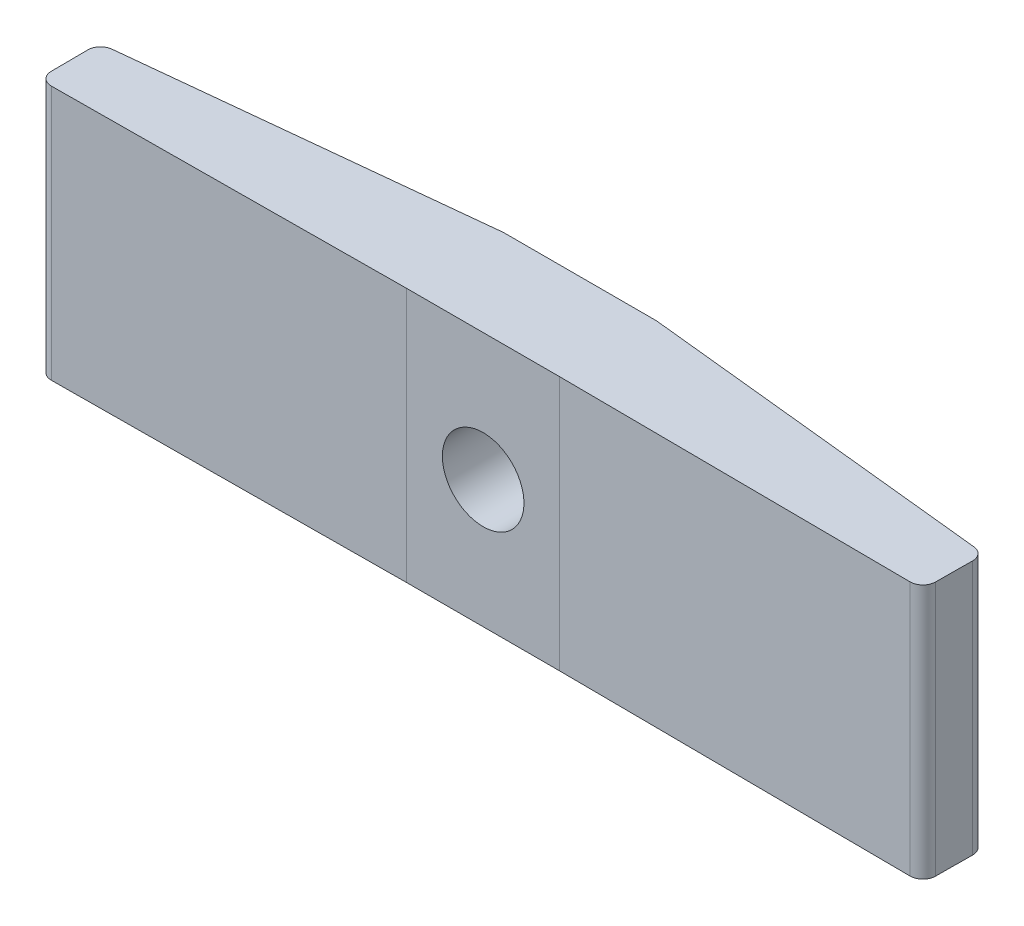
from build123d import *

# Parameters (mm, degrees)
BOSS_EXTRUDE1_DEPTH       = 10
FILLET2_R                 = 0.5
SKETCH2_R                 = 1.6
CUT_EXTRUDE1_DEPTH        = 4.896527904
REVISION_INDICATION_DEPTH = 0.4


with BuildPart() as part:
    # Sketch1 → Boss-Extrude1 (new body)
    with BuildSketch(Plane(origin=(0, 0, 0), x_dir=(1, 0, 0), z_dir=(0, 1, 0))):
        Polygon((20.35, 0.1), (14.35, 0.1), (0, 0), (-0.016724739, 2.4), (14.35, 3.9), (20.35, 3.9), (34.716724739, 2.4), (34.7, 0), align=None)
    extrude(amount=BOSS_EXTRUDE1_DEPTH)

    # Fillet2
    fillet2_edges = [part.edges().sort_by_distance(p)[0] for p in [
        (-0.016724739, 5, -2.4),
        (34.716724739, 5, -2.4),
        (34.7, 5, 0),
        (0, 5, 0),
    ]]
    fillet(fillet2_edges, radius=FILLET2_R)

    # Sketch2 → Cut-Extrude1 (cut, through all)
    with BuildSketch(Plane(origin=(0, 0, -3.9), x_dir=(-1, 0, 0), z_dir=(0, 0, -1))):
        with Locations((-17.35, 5)):
            Circle(SKETCH2_R)
    extrude(amount=-CUT_EXTRUDE1_DEPTH, mode=Mode.SUBTRACT)

    # Sketch5 → revision indication (add)
    with BuildSketch(Plane(origin=(-0.248057274, 0, -2.375847049), x_dir=(-0.994593653, 0, 0.103843465), z_dir=(-0.103843465, 0, -0.994593653))):
        with BuildLine():
            add(Edge.make_bspline(
                [(-1.785308798, 1.976923077), (-1.749947985, 1.974821832), (-1.680627244, 1.970702586), (-1.580407683, 1.942442049), (-1.489703086, 1.892261337), (-1.40890887, 1.825381725), (-1.342312834, 1.744291021), (-1.290343795, 1.654309873), (-1.262329436, 1.553251269), (-1.258240196, 1.483528859), (-1.256142132, 1.44775641)],
                knots=[0, 0, 0, 0, 0.000106068, 0.000207934, 0.000309251, 0.000414952, 0.000520654, 0.000622584, 0.00072445, 0.000831784, 0.000831784, 0.000831784, 0.000831784], degree=3))
            add(Edge.make_bspline(
                [(-1.256142132, 1.44775641), (-1.258311293, 1.412843512), (-1.262588847, 1.343995789), (-1.290279579, 1.243699421), (-1.342708899, 1.153662038), (-1.408449529, 1.071471016), (-1.489723058, 1.004449722), (-1.580622123, 0.954695939), (-1.680391977, 0.924411918), (-1.749908735, 0.920554208), (-1.785308798, 0.918589744)],
                knots=[0, 0, 0, 0, 0.000104802, 0.000206668, 0.000308598, 0.000415282, 0.000520984, 0.0006223, 0.000724523, 0.000830591, 0.000830591, 0.000830591, 0.000830591], degree=3))
            add(Edge.make_bspline(
                [(-1.785308798, 0.918589744), (-1.82073437, 0.920483127), (-1.889894366, 0.924179507), (-1.989291812, 0.955317742), (-2.080744455, 1.003983162), (-2.162002161, 1.071595984), (-2.228293388, 1.153239101), (-2.278413725, 1.244319503), (-2.308512996, 1.343708683), (-2.312471536, 1.412786963), (-2.314475465, 1.44775641)],
                knots=[0, 0, 0, 0, 0.000106068, 0.000207073, 0.000309509, 0.000415211, 0.000521895, 0.000623212, 0.000725435, 0.000830237, 0.000830237, 0.000830237, 0.000830237], degree=3))
            add(Edge.make_bspline(
                [(-2.314475465, 1.44775641), (-2.312548513, 1.483587428), (-2.308786377, 1.553543092), (-2.278350536, 1.653690044), (-2.228682266, 1.744709926), (-2.161543907, 1.825258007), (-2.080764113, 1.892726399), (-1.989512426, 1.941829667), (-1.889654975, 1.970931558), (-1.820694086, 1.974891267), (-1.785308798, 1.976923077)],
                knots=[0, 0, 0, 0, 0.000107334, 0.000209557, 0.000310874, 0.000416575, 0.000522277, 0.000624713, 0.000725357, 0.000831425, 0.000831425, 0.000831425, 0.000831425], degree=3))
        make_face()
        with BuildLine():
            add(Edge.make_bspline(
                [(-4.146206234, 1.976923077), (-4.110845421, 1.974821832), (-4.04152468, 1.970702586), (-3.941305118, 1.942442049), (-3.850600522, 1.892261337), (-3.769806306, 1.825381725), (-3.70321027, 1.744291021), (-3.651241231, 1.654309873), (-3.623226872, 1.553251269), (-3.619137632, 1.483528859), (-3.617039568, 1.44775641)],
                knots=[0, 0, 0, 0, 0.000106068, 0.000207934, 0.000309251, 0.000414952, 0.000520654, 0.000622584, 0.00072445, 0.000831784, 0.000831784, 0.000831784, 0.000831784], degree=3))
            add(Edge.make_bspline(
                [(-3.617039568, 1.44775641), (-3.619208729, 1.412843512), (-3.623486283, 1.343995789), (-3.651177015, 1.243699421), (-3.703606335, 1.153662038), (-3.769346965, 1.071471016), (-3.850620494, 1.004449722), (-3.941519559, 0.954695939), (-4.041289413, 0.924411918), (-4.110806171, 0.920554208), (-4.146206234, 0.918589744)],
                knots=[0, 0, 0, 0, 0.000104802, 0.000206668, 0.000308598, 0.000415282, 0.000520984, 0.0006223, 0.000724523, 0.000830591, 0.000830591, 0.000830591, 0.000830591], degree=3))
            add(Edge.make_bspline(
                [(-4.146206234, 0.918589744), (-4.181631806, 0.920483127), (-4.250791802, 0.924179507), (-4.350189248, 0.955317742), (-4.441641891, 1.003983162), (-4.522899597, 1.071595984), (-4.589190824, 1.153239101), (-4.639311161, 1.244319503), (-4.669410431, 1.343708683), (-4.673368972, 1.412786963), (-4.675372901, 1.44775641)],
                knots=[0, 0, 0, 0, 0.000106068, 0.000207073, 0.000309509, 0.000415211, 0.000521895, 0.000623212, 0.000725435, 0.000830237, 0.000830237, 0.000830237, 0.000830237], degree=3))
            add(Edge.make_bspline(
                [(-4.675372901, 1.44775641), (-4.673445949, 1.483587428), (-4.669683813, 1.553543092), (-4.639247972, 1.653690044), (-4.589579702, 1.744709926), (-4.522441343, 1.825258007), (-4.441661549, 1.892726399), (-4.350409862, 1.941829667), (-4.25055241, 1.970931558), (-4.181591522, 1.974891267), (-4.146206234, 1.976923077)],
                knots=[0, 0, 0, 0, 0.000107334, 0.000209557, 0.000310874, 0.000416575, 0.000522277, 0.000624713, 0.000725357, 0.000831425, 0.000831425, 0.000831425, 0.000831425], degree=3))
        make_face()
        with BuildLine():
            add(Edge.make_bspline(
                [(-6.50710367, 1.976923077), (-6.471742857, 1.974821832), (-6.402422116, 1.970702586), (-6.302202554, 1.942442049), (-6.211497957, 1.892261337), (-6.130703742, 1.825381725), (-6.064107706, 1.744291021), (-6.012138667, 1.654309873), (-5.984124308, 1.553251269), (-5.980035068, 1.483528859), (-5.977937003, 1.44775641)],
                knots=[0, 0, 0, 0, 0.000106068, 0.000207934, 0.000309251, 0.000414952, 0.000520654, 0.000622584, 0.00072445, 0.000831784, 0.000831784, 0.000831784, 0.000831784], degree=3))
            add(Edge.make_bspline(
                [(-5.977937003, 1.44775641), (-5.980106165, 1.412843512), (-5.984383719, 1.343995789), (-6.012074451, 1.243699421), (-6.064503771, 1.153662038), (-6.130244401, 1.071471016), (-6.21151793, 1.004449722), (-6.302416994, 0.954695939), (-6.402186849, 0.924411918), (-6.471703607, 0.920554208), (-6.50710367, 0.918589744)],
                knots=[0, 0, 0, 0, 0.000104802, 0.000206668, 0.000308598, 0.000415282, 0.000520984, 0.0006223, 0.000724523, 0.000830591, 0.000830591, 0.000830591, 0.000830591], degree=3))
            add(Edge.make_bspline(
                [(-6.50710367, 0.918589744), (-6.542529242, 0.920483127), (-6.611689237, 0.924179507), (-6.711086684, 0.955317742), (-6.802539327, 1.003983162), (-6.883797033, 1.071595984), (-6.95008826, 1.153239101), (-7.000208597, 1.244319503), (-7.030307867, 1.343708683), (-7.034266408, 1.412786963), (-7.036270337, 1.44775641)],
                knots=[0, 0, 0, 0, 0.000106068, 0.000207073, 0.000309509, 0.000415211, 0.000521895, 0.000623212, 0.000725435, 0.000830237, 0.000830237, 0.000830237, 0.000830237], degree=3))
            add(Edge.make_bspline(
                [(-7.036270337, 1.44775641), (-7.034343385, 1.483587428), (-7.030581249, 1.553543092), (-7.000145408, 1.653690044), (-6.950477138, 1.744709926), (-6.883338779, 1.825258007), (-6.802558985, 1.892726399), (-6.711307298, 1.941829667), (-6.611449846, 1.970931558), (-6.542488958, 1.974891267), (-6.50710367, 1.976923077)],
                knots=[0, 0, 0, 0, 0.000107334, 0.000209557, 0.000310874, 0.000416575, 0.000522277, 0.000624713, 0.000725357, 0.000831425, 0.000831425, 0.000831425, 0.000831425], degree=3))
        make_face()
        with BuildLine():
            add(Edge.make_bspline(
                [(-8.868001106, 1.976923077), (-8.832640293, 1.974821832), (-8.763319552, 1.970702586), (-8.66309999, 1.942442049), (-8.572395393, 1.892261337), (-8.491601178, 1.825381725), (-8.425005142, 1.744291021), (-8.373036103, 1.654309873), (-8.345021744, 1.553251269), (-8.340932504, 1.483528859), (-8.338834439, 1.44775641)],
                knots=[0, 0, 0, 0, 0.000106068, 0.000207934, 0.000309251, 0.000414952, 0.000520654, 0.000622584, 0.00072445, 0.000831784, 0.000831784, 0.000831784, 0.000831784], degree=3))
            add(Edge.make_bspline(
                [(-8.338834439, 1.44775641), (-8.341003601, 1.412843512), (-8.345281155, 1.343995789), (-8.372971887, 1.243699421), (-8.425401207, 1.153662038), (-8.491141837, 1.071471016), (-8.572415366, 1.004449722), (-8.66331443, 0.954695939), (-8.763084284, 0.924411918), (-8.832601042, 0.920554208), (-8.868001106, 0.918589744)],
                knots=[0, 0, 0, 0, 0.000104802, 0.000206668, 0.000308598, 0.000415282, 0.000520984, 0.0006223, 0.000724523, 0.000830591, 0.000830591, 0.000830591, 0.000830591], degree=3))
            add(Edge.make_bspline(
                [(-8.868001106, 0.918589744), (-8.903426678, 0.920483127), (-8.972586673, 0.924179507), (-9.07198412, 0.955317742), (-9.163436763, 1.003983162), (-9.244694469, 1.071595984), (-9.310985696, 1.153239101), (-9.361106033, 1.244319503), (-9.391205303, 1.343708683), (-9.395163844, 1.412786963), (-9.397167773, 1.44775641)],
                knots=[0, 0, 0, 0, 0.000106068, 0.000207073, 0.000309509, 0.000415211, 0.000521895, 0.000623212, 0.000725435, 0.000830237, 0.000830237, 0.000830237, 0.000830237], degree=3))
            add(Edge.make_bspline(
                [(-9.397167773, 1.44775641), (-9.395240821, 1.483587428), (-9.391478685, 1.553543092), (-9.361042844, 1.653690044), (-9.311374574, 1.744709926), (-9.244236214, 1.825258007), (-9.16345642, 1.892726399), (-9.072204734, 1.941829667), (-8.972347282, 1.970931558), (-8.903386394, 1.974891267), (-8.868001106, 1.976923077)],
                knots=[0, 0, 0, 0, 0.000107334, 0.000209557, 0.000310874, 0.000416575, 0.000522277, 0.000624713, 0.000725357, 0.000831425, 0.000831425, 0.000831425, 0.000831425], degree=3))
        make_face()
    extrude(amount=REVISION_INDICATION_DEPTH)


solid = part.part
